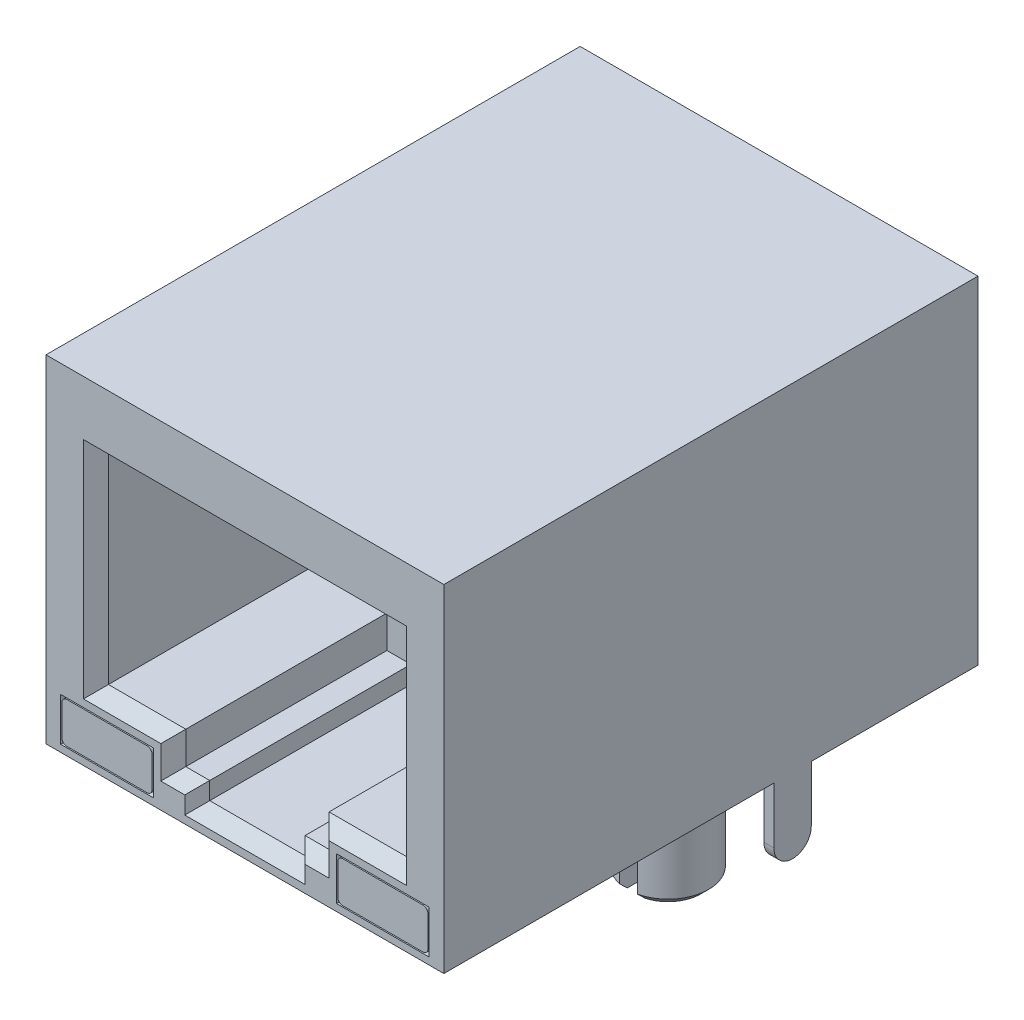
from build123d import *

# Parameters (mm, degrees)
SKETCH2_W            = 15.94
SKETCH2_H            = 21.4
BOSS_EXTRUDE1_DEPTH  = 13.5
CUT_EXTRUDE1_DEPTH   = 8.56
CHAMFER1_SIZE        = 0.5
SKETCH4_W            = 3.71
SKETCH4_H            = 1.73
CUT_EXTRUDE2_DEPTH   = 8
BOSS_EXTRUDE2_DEPTH  = 8
BOSS_EXTRUDE5_DEPTH  = 0.25
LPATTERN1_COUNT      = 8
LPATTERN1_PITCH      = 1
BOSS_EXTRUDE7_START  = 7.97
BOSS_EXTRUDE7_DEPTH  = 0.4
BOSS_EXTRUDE8_START  = -7.57
BOSS_EXTRUDE8_DEPTH  = 0.4
SKETCH9_R            = 1.625
BOSS_EXTRUDE9_DEPTH  = 3
CUT_EXTRUDE3_DEPTH   = 3
CHAMFER2_SIZE        = 0.3
SKETCH11_R           = 0.445
BOSS_EXTRUDE10_DEPTH = 3
CHAMFER3_SIZE        = 0.15


with BuildPart() as part:
    # Sketch2 → Boss-Extrude1 (new body)
    with BuildSketch(Plane(origin=(0, 0, 0), x_dir=(1, 0, 0), z_dir=(0, 1, 0))):
        Rectangle(SKETCH2_W, SKETCH2_H)
    extrude(amount=BOSS_EXTRUDE1_DEPTH)

    # Sketch3 → Cut-Extrude1 (cut)
    with BuildSketch(Plane.XY.offset(10.7)):
        Polygon((-5.97, 10.81), (5.97, 10.81), (5.97, 2.81), (2.87, 2.81), (2.87, 1.51), (1.91, 1.51), (1.91, 0.81), (-1.91, 0.81), (-1.91, 1.51), (-2.87, 1.51), (-2.87, 2.81), (-5.97, 2.81), align=None)
    extrude(amount=-CUT_EXTRUDE1_DEPTH, mode=Mode.SUBTRACT)

    # Chamfer1
    chamfer1_edges = [part.edges().sort_by_distance(p)[0] for p in [
        (-4.42, 2.81, 10.7),
        (-2.87, 2.16, 10.7),
        (-2.39, 1.51, 10.7),
        (-1.91, 1.16, 10.7),
        (0, 0.81, 10.7),
        (1.91, 1.16, 10.7),
        (2.39, 1.51, 10.7),
        (2.87, 2.16, 10.7),
        (4.42, 2.81, 10.7),
        (5.97, 6.81, 10.7),
        (-5.97, 6.81, 10.7),
        (0, 10.81, 10.7),
    ]]
    chamfer(chamfer1_edges, length=CHAMFER1_SIZE)

    # Sketch4 → Cut-Extrude2 (cut)
    with BuildSketch(Plane.XY.offset(10.7)):
        with Locations((-5.525, 1.145)):
            Rectangle(SKETCH4_W, SKETCH4_H)
        with Locations((5.525, 1.145)):
            Rectangle(SKETCH4_W, SKETCH4_H)
    extrude(amount=-CUT_EXTRUDE2_DEPTH, mode=Mode.SUBTRACT)

    # Sketch5 → Boss-Extrude2 (add)
    with BuildSketch(Plane.XY.offset(2.7)):
        with BuildLine():
            Line((-7.13, 1.96), (-3.92, 1.96))
            ThreePointArc((-3.92, 1.96), (-3.778578644, 1.901421356), (-3.72, 1.76))
            Line((-3.72, 1.76), (-3.72, 0.53))
            ThreePointArc((-3.72, 0.53), (-3.778578644, 0.388578644), (-3.92, 0.33))
            Line((-3.92, 0.33), (-7.13, 0.33))
            ThreePointArc((-7.13, 0.33), (-7.271421356, 0.388578644), (-7.33, 0.53))
            Line((-7.33, 0.53), (-7.33, 1.76))
            ThreePointArc((-7.33, 1.76), (-7.271421356, 1.901421356), (-7.13, 1.96))
        make_face()
        with BuildLine():
            Line((3.72, 1.76), (3.72, 0.53))
            ThreePointArc((3.72, 0.53), (3.778578644, 0.388578644), (3.92, 0.33))
            Line((3.92, 0.33), (7.13, 0.33))
            ThreePointArc((7.13, 0.33), (7.271421356, 0.388578644), (7.33, 0.53))
            Line((7.33, 0.53), (7.33, 1.76))
            ThreePointArc((7.33, 1.76), (7.271421356, 1.901421356), (7.13, 1.96))
            Line((7.13, 1.96), (3.92, 1.96))
            ThreePointArc((3.92, 1.96), (3.778578644, 1.901421356), (3.72, 1.76))
        make_face()
    extrude(amount=BOSS_EXTRUDE2_DEPTH)

    # Sketch6 → Boss-Extrude5 (add, symmetric)
    with BuildSketch(Plane.ZY.offset(-3.47)):
        with BuildLine():
            Line((9.157258215, 10.804234071), (9.157258215, 10.623877591))
            ThreePointArc((9.157258215, 10.623877591), (9.087595817, 10.431667837), (8.910960953, 10.328723367))
            Line((8.910960953, 10.328723367), (2.14, 9.096760174))
            Line((2.14, 9.096760174), (2.14, 9.52745757))
            Line((2.14, 9.52745757), (9.157258215, 10.804234071))
        make_face()
    boss_extrude5 = extrude(amount=BOSS_EXTRUDE5_DEPTH, both=True)

    # LPattern1: Boss-Extrude5 ×8
    with Locations(*[(-i * LPATTERN1_PITCH, 0, 0) for i in range(1, LPATTERN1_COUNT)]):
        add(boss_extrude5)

    # Sketch8 → Boss-Extrude7 (add)
    with BuildSketch(Plane(origin=(0, 0, 0), x_dir=(0, 0, -1), z_dir=(1, 0, 0)).offset(BOSS_EXTRUDE7_START)):
        with BuildLine():
            Line((4.02, 0), (4.02, -2.25))
            ThreePointArc((4.02, -2.25), (3.27, -3), (2.52, -2.25))
            Line((2.52, -2.25), (2.52, 0))
            Line((2.52, 0), (4.02, 0))
        make_face()
    extrude(amount=-BOSS_EXTRUDE7_DEPTH)

    # Sketch8_2 → Boss-Extrude8 (add)
    with BuildSketch(Plane(origin=(0, 0, 0), x_dir=(0, 0, -1), z_dir=(1, 0, 0)).offset(BOSS_EXTRUDE8_START)):
        with BuildLine():
            Line((4.02, 0), (4.02, -2.25))
            ThreePointArc((4.02, -2.25), (3.27, -3), (2.52, -2.25))
            Line((2.52, -2.25), (2.52, 0))
            Line((2.52, 0), (4.02, 0))
        make_face()
    extrude(amount=-BOSS_EXTRUDE8_DEPTH)

    # Sketch9 → Boss-Extrude9 (add)
    with BuildSketch(Plane.XZ):
        with Locations((6.030646147, -0.22)):
            Circle(SKETCH9_R)
        with Locations((-6.030646147, -0.22)):
            Circle(SKETCH9_R)
    extrude(amount=BOSS_EXTRUDE9_DEPTH)

    # Sketch10 → Cut-Extrude3 (cut)
    with BuildSketch(Plane.XZ):
        with BuildLine():
            ThreePointArc((-5.673759882, 1.36532558), (-6.030646147, 1.405), (-6.387532412, 1.36532558))
            Line((-6.387532412, 1.36532558), (-6.387532412, -1.80532558))
            ThreePointArc((-6.387532412, -1.80532558), (-6.030646147, -1.845), (-5.673759882, -1.80532558))
            Line((-5.673759882, -1.80532558), (-5.673759882, 1.36532558))
        make_face()
        with BuildLine():
            ThreePointArc((6.387532412, 1.36532558), (6.030646147, 1.405), (5.673759882, 1.36532558))
            Line((5.673759882, 1.36532558), (5.673759882, -1.80532558))
            ThreePointArc((5.673759882, -1.80532558), (6.030646147, -1.845), (6.387532412, -1.80532558))
            Line((6.387532412, -1.80532558), (6.387532412, 1.36532558))
        make_face()
    extrude(amount=CUT_EXTRUDE3_DEPTH, mode=Mode.SUBTRACT)

    # Chamfer2
    chamfer2_edges = [part.edges().sort_by_distance(p)[0] for p in [
        (7.655646147, -3, -0.22),
        (4.405646147, -3, -0.22),
        (-4.405646147, -3, -0.22),
        (-7.655646147, -3, -0.22),
    ]]
    chamfer(chamfer2_edges, length=CHAMFER2_SIZE)

    # Sketch11 → Boss-Extrude10 (add)
    with BuildSketch(Plane.XZ):
        with Locations((-5.013424508, -9.11)):
            Circle(SKETCH11_R)
        with Locations((-2.473424508, -9.11)):
            Circle(SKETCH11_R)
        with Locations((0.066575492, -9.11)):
            Circle(SKETCH11_R)
        with Locations((2.606575492, -9.11)):
            Circle(SKETCH11_R)
        with Locations((-3.719101646, -6.57)):
            Circle(SKETCH11_R)
        with Locations((-1.179101646, -6.57)):
            Circle(SKETCH11_R)
        with Locations((1.360898354, -6.57)):
            Circle(SKETCH11_R)
        with Locations((3.900898354, -6.57)):
            Circle(SKETCH11_R)
    extrude(amount=BOSS_EXTRUDE10_DEPTH)

    # Chamfer3
    chamfer3_edges = [part.edges().sort_by_distance(p)[0] for p in [
        (3.455898354, -3, -6.57),
        (2.161575492, -3, -9.11),
        (0.915898354, -3, -6.57),
        (-0.378424508, -3, -9.11),
        (-1.624101646, -3, -6.57),
        (-2.918424508, -3, -9.11),
        (-4.164101646, -3, -6.57),
        (-5.458424508, -3, -9.11),
    ]]
    chamfer(chamfer3_edges, length=CHAMFER3_SIZE)


solid = part.part
